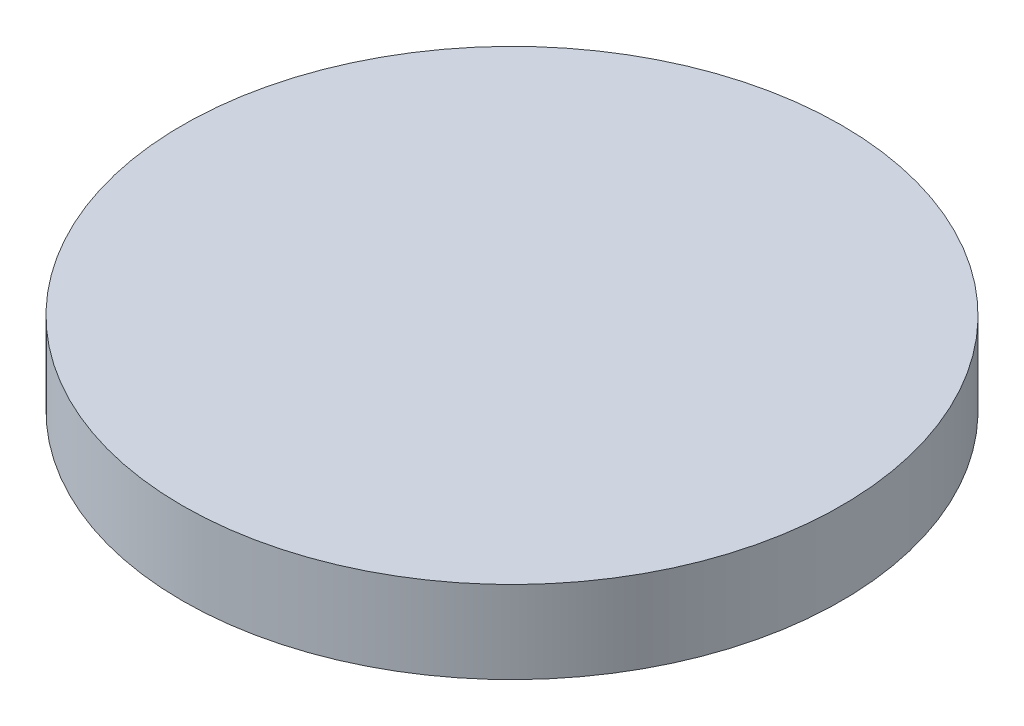
from build123d import *

# Parameters (mm, degrees)
SKETCH1_R           = 12.7
BOSS_EXTRUDE1_DEPTH = 3.175


with BuildPart() as part:
    # Sketch1 → Boss-Extrude1 (new body)
    with BuildSketch(Plane(origin=(0, 0, 0), x_dir=(1, 0, 0), z_dir=(0, 1, 0))):
        Circle(SKETCH1_R)
    extrude(amount=BOSS_EXTRUDE1_DEPTH)


solid = part.part
